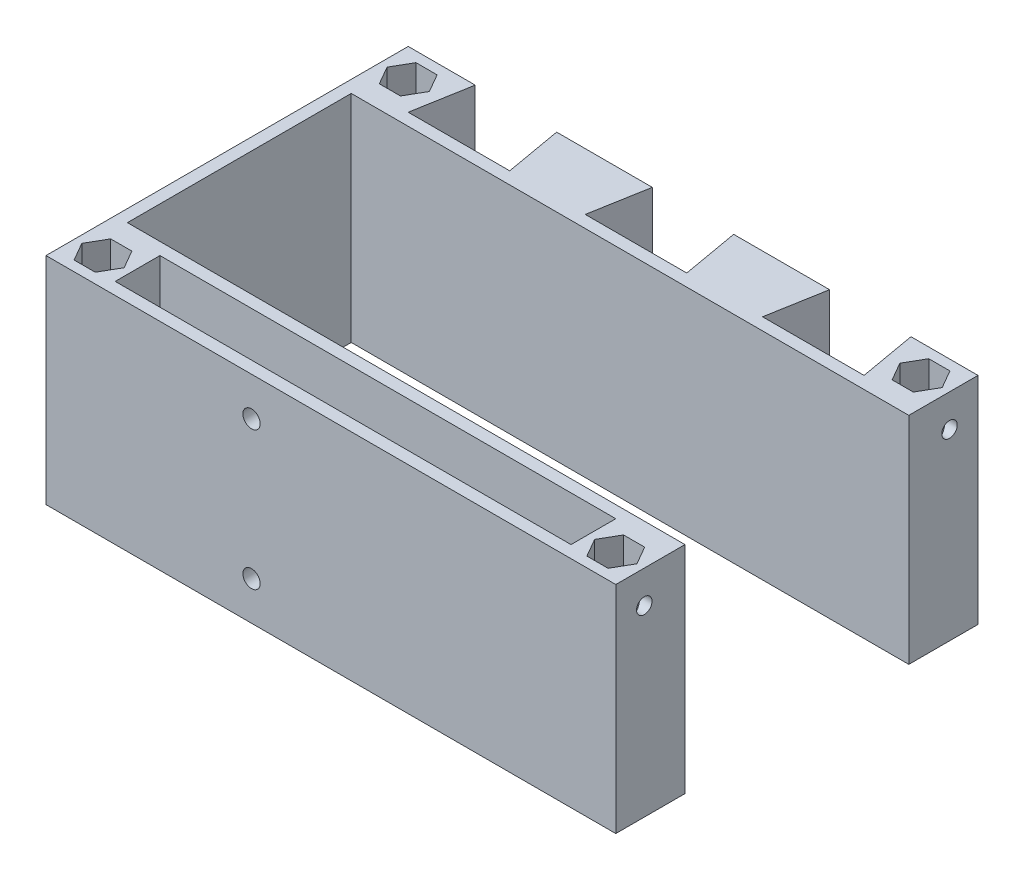
from build123d import *

# Parameters (mm, degrees)
SKETCH1_W           = 112
SKETCH1_H           = 11
BOSS_EXTRUDE2_DEPTH = 53
SKETCH2_R           = 1.9
CUT_EXTRUDE1_DEPTH  = 9.5
SKETCH3_R           = 1.9
CUT_EXTRUDE2_DEPTH  = 9.5
CUT_EXTRUDE3_REACH  = 91
SKETCH4_R           = 2.125
SKETCH5_R           = 2.75
BOSS_EXTRUDE6_DEPTH = 12


with BuildPart() as part:
    # Sketch1 → Boss-Extrude2 (new body)
    with BuildSketch(Plane(origin=(0, 0, 0), x_dir=(1, 0, 0), z_dir=(0, 1, 0))):
        Polygon((140, -17), (140, 0), (3, 0), (3, 55), (140, 55), (140, 72), (123.53142227, 72), (126, 58), (101.06284454, 58), (103.53142227, 72), (79.96857773, 72), (82.43715546, 58), (57.5, 58), (59.96857773, 72), (36.46857773, 72), (38.93715546, 58), (14, 58), (16.46857773, 72), (0, 72), (0, -17), align=None)
        with Locations((70, -8.5)):
            Rectangle(SKETCH1_W, SKETCH1_H, mode=Mode.SUBTRACT)
        Polygon((4.401923789, -5.5), (9.598076211, -5.5), (12.196152423, -10), (9.598076211, -14.5), (4.401923789, -14.5), (1.803847577, -10), align=None, mode=Mode.SUBTRACT)
        Polygon((12.196152423, 65), (9.598076211, 60.5), (4.401923789, 60.5), (1.803847577, 65), (4.401923789, 69.5), (9.598076211, 69.5), align=None, mode=Mode.SUBTRACT)
        Polygon((127.803847577, -10), (130.401923789, -5.5), (135.598076211, -5.5), (138.196152423, -10), (135.598076211, -14.5), (130.401923789, -14.5), align=None, mode=Mode.SUBTRACT)
        Polygon((135.598076211, 60.5), (130.401923789, 60.5), (127.803847577, 65), (130.401923789, 69.5), (135.598076211, 69.5), (138.196152423, 65), align=None, mode=Mode.SUBTRACT)
    extrude(amount=BOSS_EXTRUDE2_DEPTH)

    # Sketch2 → Cut-Extrude1 (cut)
    with BuildSketch(Plane(origin=(140, 0, 0), x_dir=(0, 0, -1), z_dir=(1, 0, 0))):
        with Locations((-10, 45)):
            Circle(SKETCH2_R)
        with Locations((65, 45)):
            Circle(SKETCH2_R)
    extrude(amount=-CUT_EXTRUDE1_DEPTH, mode=Mode.SUBTRACT)

    # Sketch3 → Cut-Extrude2 (cut)
    with BuildSketch(Plane.ZY):
        with Locations((-65, 45)):
            Circle(SKETCH3_R)
        with Locations((10, 45)):
            Circle(SKETCH3_R)
    extrude(amount=-CUT_EXTRUDE2_DEPTH, mode=Mode.SUBTRACT)

    # Sketch4 → Cut-Extrude3 (cut, up to next)
    with BuildSketch(Plane.XY.offset(17), mode=Mode.PRIVATE) as cut_extrude3_sk1:
        with Locations((50.5, 43.5)):
            Circle(SKETCH4_R)
    cut_extrude3_tool1 = extrude(cut_extrude3_sk1.sketch, amount=-CUT_EXTRUDE3_REACH, mode=Mode.PRIVATE) & part.part
    add(cut_extrude3_tool1.solids().sort_by_distance((50.5, 43.5, 17))[0], mode=Mode.SUBTRACT)
    # Sketch4 → Cut-Extrude3 (cut, up to next)
    with BuildSketch(Plane.XY.offset(17), mode=Mode.PRIVATE) as cut_extrude3_sk2:
        with Locations((50.5, 9.5)):
            Circle(SKETCH4_R)
    cut_extrude3_tool2 = extrude(cut_extrude3_sk2.sketch, amount=-CUT_EXTRUDE3_REACH, mode=Mode.PRIVATE) & part.part
    add(cut_extrude3_tool2.solids().sort_by_distance((50.5, 9.5, 17))[0], mode=Mode.SUBTRACT)

    # Sketch5 → Boss-Extrude6 (add)
    with BuildSketch(Plane.XZ):
        Polygon((3.904199133, -59.637915608), (10.095800867, -59.637915608), (13.191601734, -65), (10.095800867, -70.362084392), (3.904199133, -70.362084392), (0.808398266, -65), align=None)
        with Locations((7, -65)):
            Circle(SKETCH5_R, mode=Mode.SUBTRACT)
        Polygon((13.191601734, 10), (10.095800867, 15.362084392), (3.904199133, 15.362084392), (0.808398266, 10), (3.904199133, 4.637915608), (10.095800867, 4.637915608), align=None)
        with Locations((7, 10)):
            Circle(SKETCH5_R, mode=Mode.SUBTRACT)
        Polygon((139.122867425, -65.057948728), (136.03156068, -59.693272163), (129.83996112, -59.688084053), (126.739668304, -65.047572507), (129.830975049, -70.412249071), (136.022574609, -70.417437182), align=None)
        with Locations((132.931267865, -65.052760617)):
            Circle(SKETCH5_R, mode=Mode.SUBTRACT)
        Polygon((129.893819578, 4.587724599), (126.802512833, 9.952401164), (129.902805649, 15.311889618), (136.094405209, 15.306701507), (139.185711954, 9.942024942), (136.085419138, 4.582536488), align=None)
        with Locations((132.994112394, 9.947213053)):
            Circle(SKETCH5_R, mode=Mode.SUBTRACT)
    extrude(amount=-BOSS_EXTRUDE6_DEPTH)


solid = part.part
